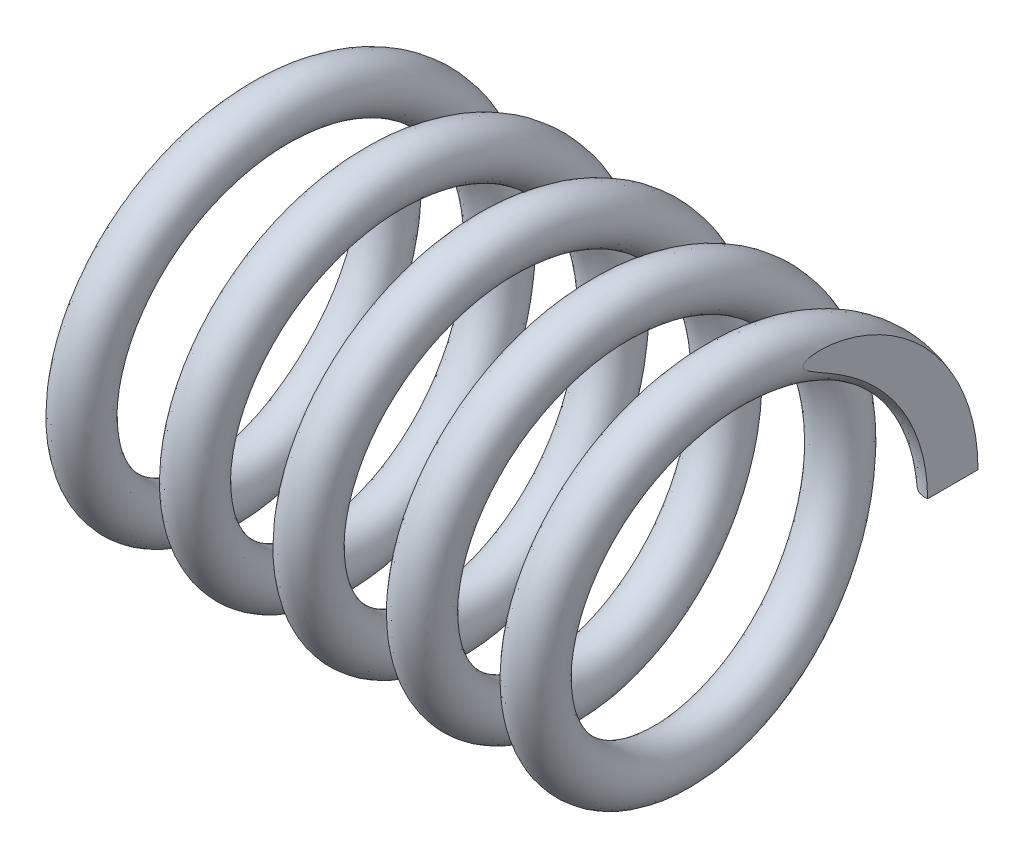
from build123d import *

# Parameters (mm, degrees)
SWEEP_1_PITCH       = 18
SWEEP_1_HEIGHT      = 90
SWEEP_1_RADIUS      = 28.5
SWEEP_1_START_ANGLE = 180
SWEEP_1_PROFILE_R   = 4
SKETCH_3_W          = 78.192103194
SKETCH_3_H          = 87.894164892
CUT_EXTRUDE_1_DEPTH = 4.979943857
SKETCH_4_W          = 82.593175774
SKETCH_4_H          = 82.860467604
CUT_EXTRUDE_2_DEPTH = 4.979943857


with BuildPart() as part:
    # По траектории1: sweep along a helix
    with BuildLine() as sweep_1_path:
        add(Helix(SWEEP_1_PITCH, SWEEP_1_HEIGHT, SWEEP_1_RADIUS, center=(0, 0, 0), direction=(1, 0, 0), lefthand=True, mode=Mode.PRIVATE).rotate(Axis((0, 0, 0), (1, 0, 0)), SWEEP_1_START_ANGLE))
    # По траектории1 profile (on start of the path) → По траектории1 (sweep)
    with BuildSketch(Plane(origin=(0, 0, -28.5), x_dir=(-0.994985939, -0.100014903, 0), z_dir=(0.100014903, -0.994985939, 0))):
        Circle(SWEEP_1_PROFILE_R)
    sweep(path=sweep_1_path.line, is_frenet=True)

    # Эскиз3 → Вырез-Вытянуть1 (cut, through all)
    with BuildSketch(Plane(origin=(0, 0, 0), x_dir=(0, 0, -1), z_dir=(1, 0, 0))):
        Rectangle(SKETCH_3_W, SKETCH_3_H)
    extrude(amount=-CUT_EXTRUDE_1_DEPTH, mode=Mode.SUBTRACT)

    # Эскиз4 → Вырез-Вытянуть2 (cut, through all)
    with BuildSketch(Plane(origin=(90, 0, 0), x_dir=(0, 0, -1), z_dir=(1, 0, 0))):
        Rectangle(SKETCH_4_W, SKETCH_4_H)
    extrude(amount=CUT_EXTRUDE_2_DEPTH, mode=Mode.SUBTRACT)


solid = part.part
